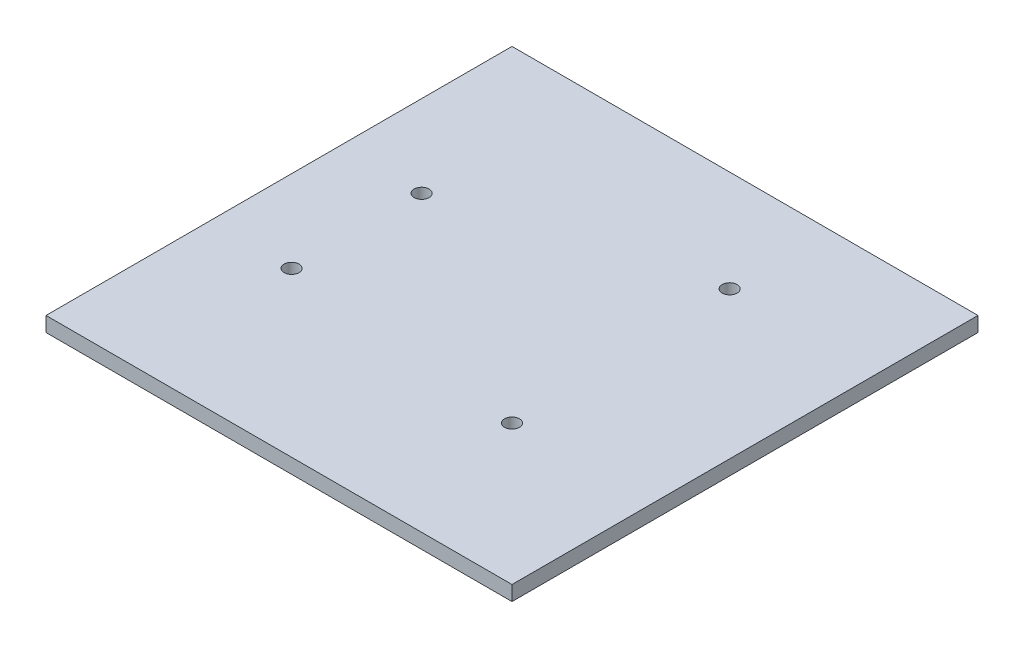
from build123d import *

# Parameters (mm, degrees)
SKETCH1_W           = 100
SKETCH1_H           = 100
BOSS_EXTRUDE1_DEPTH = 3.18
SKETCH2_R           = 1.6
CUT_EXTRUDE1_DEPTH  = 4.18


with BuildPart() as part:
    # Sketch1 → Boss-Extrude1 (new body)
    with BuildSketch(Plane(origin=(0, 0, 0), x_dir=(1, 0, 0), z_dir=(0, 1, 0))):
        Rectangle(SKETCH1_W, SKETCH1_H)
    extrude(amount=BOSS_EXTRUDE1_DEPTH)

    # Sketch2 → Cut-Extrude1 (cut, through all)
    with BuildSketch(Plane(origin=(0, 3.18, 0), x_dir=(1, 0, 0), z_dir=(0, 1, 0))):
        with Locations((-32.4, 13)):
            Circle(SKETCH2_R)
        with Locations((-32.4, -14.9)):
            Circle(SKETCH2_R)
        with Locations((18.4, 28.3)):
            Circle(SKETCH2_R)
        with Locations((20, -20)):
            Circle(SKETCH2_R)
    extrude(amount=-CUT_EXTRUDE1_DEPTH, mode=Mode.SUBTRACT)


solid = part.part
